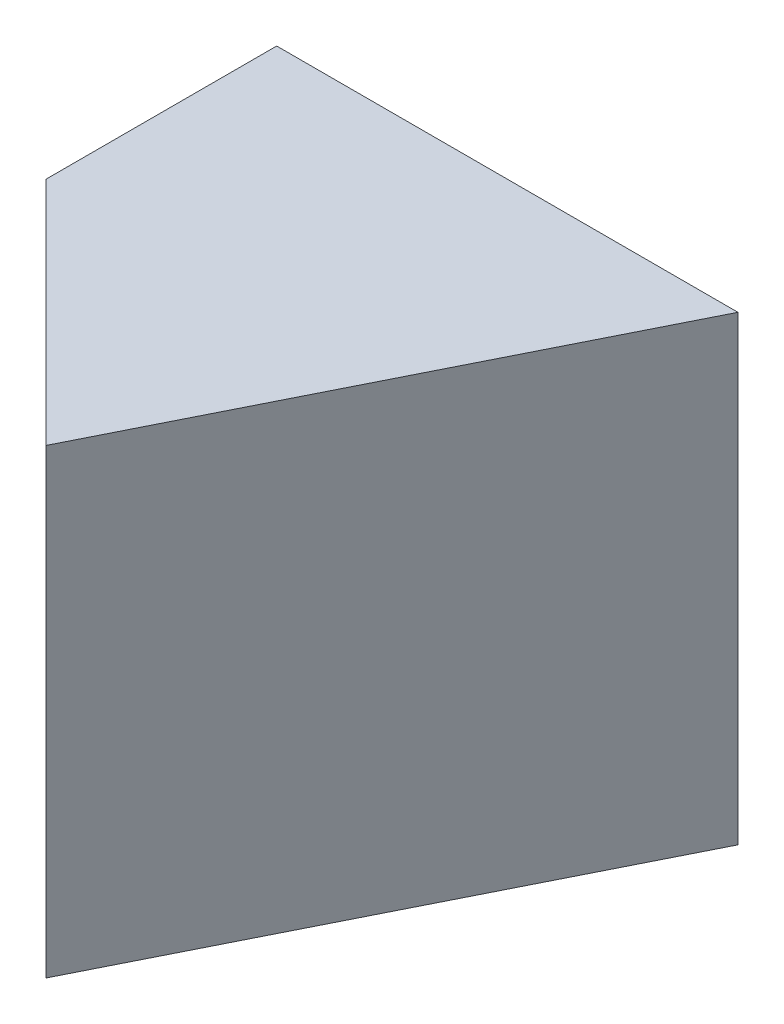
from build123d import *

# Parameters (mm, degrees)
SKETCH1_W           = 20
SKETCH1_H           = 20
BOSS_EXTRUDE1_DEPTH = 20
CUT_EXTRUDE1_DEPTH  = 20
CUT_EXTRUDE2_DEPTH  = 20


with BuildPart() as part:
    # Sketch1 → Boss-Extrude1 (new body)
    with BuildSketch(Plane.XY):
        with Locations((10, 10)):
            Rectangle(SKETCH1_W, SKETCH1_H)
    extrude(amount=BOSS_EXTRUDE1_DEPTH)

    # Sketch2 → Cut-Extrude1 (cut)
    with BuildSketch(Plane(origin=(0, 20, 0), x_dir=(1, 0, 0), z_dir=(0, 1, 0))):
        Polygon((20, 0), (10, -20), (20, -20), align=None)
    extrude(amount=-CUT_EXTRUDE1_DEPTH, mode=Mode.SUBTRACT)

    # Sketch3 → Cut-Extrude2 (cut)
    with BuildSketch(Plane(origin=(0, 20, 0), x_dir=(1, 0, 0), z_dir=(0, 1, 0))):
        Polygon((0, -20), (10, -20), (0, -10), align=None)
    extrude(amount=-CUT_EXTRUDE2_DEPTH, mode=Mode.SUBTRACT)


solid = part.part
